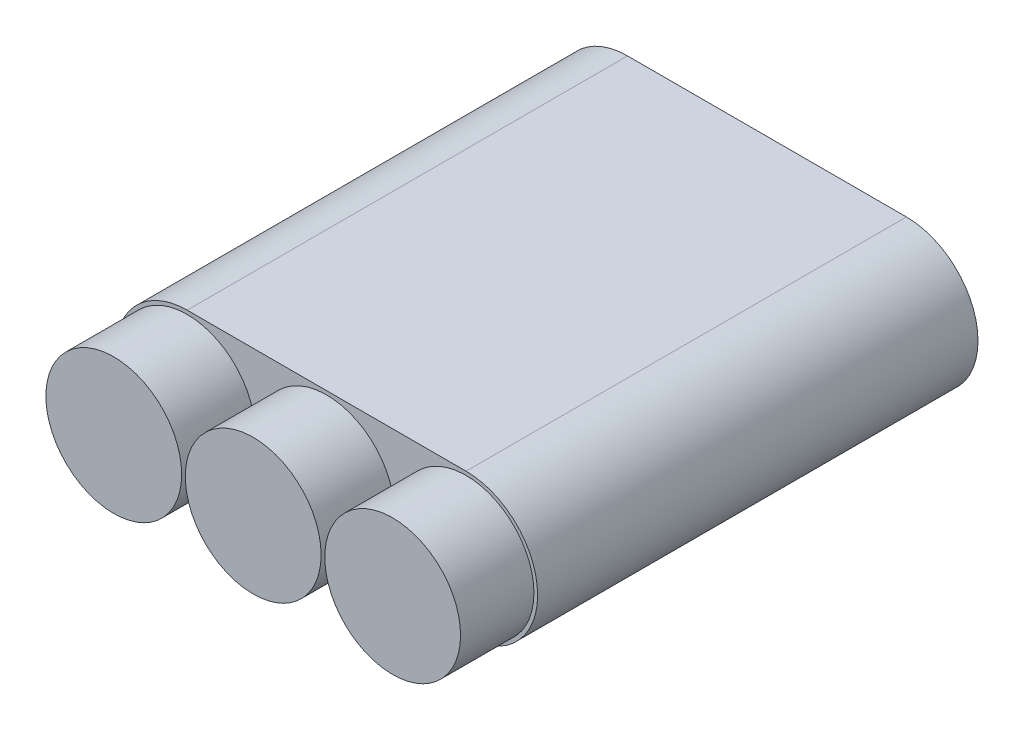
from build123d import *

# Parameters (mm, degrees)
SKIZZE1_R                         = 9.25
AUFSATZ_LINEAR_AUSTRAGEN1_DEPTH   = 10
AUFSATZ_LINEAR_AUSTRAGEN1_2_DEPTH = 10
AUFSATZ_LINEAR_AUSTRAGEN1_3_DEPTH = 10
AUFSATZ_LINEAR_AUSTRAGEN7_DEPTH   = 60


with BuildPart() as part:
    # Skizze1 → Aufsatz-Linear austragen1 (new body)
    with BuildSketch(Plane.XY):
        Circle(SKIZZE1_R)
    extrude(amount=AUFSATZ_LINEAR_AUSTRAGEN1_DEPTH)



with BuildPart() as body_2:
    # Skizze1 → Aufsatz-Linear austragen1 2 (new body)
    with BuildSketch(Plane.XY):
        with Locations((19, 0)):
            Circle(SKIZZE1_R)
    extrude(amount=AUFSATZ_LINEAR_AUSTRAGEN1_2_DEPTH)


with BuildPart() as body_3:
    # Skizze1 → Aufsatz-Linear austragen1 3 (new body)
    with BuildSketch(Plane.XY):
        with Locations((-19, 0)):
            Circle(SKIZZE1_R)
    extrude(amount=AUFSATZ_LINEAR_AUSTRAGEN1_3_DEPTH)


with BuildPart() as part_1:
    add(part.part)

    add(body_2.part)  # Aufsatz-Linear austragen7 merges body 2

    add(body_3.part)  # Aufsatz-Linear austragen7 merges body 3
    # Skizze1_5 → Aufsatz-Linear austragen7 (add)
    with BuildSketch(Plane.XY):
        with BuildLine():
            Line((19, 9.75), (-19, 9.75))
            ThreePointArc((-19, 9.75), (-28.75, 0), (-19, -9.75))
            Line((-19, -9.75), (19, -9.75))
            ThreePointArc((19, -9.75), (28.75, 0), (19, 9.75))
        make_face()
    extrude(amount=-AUFSATZ_LINEAR_AUSTRAGEN7_DEPTH)


solid = part_1.part
